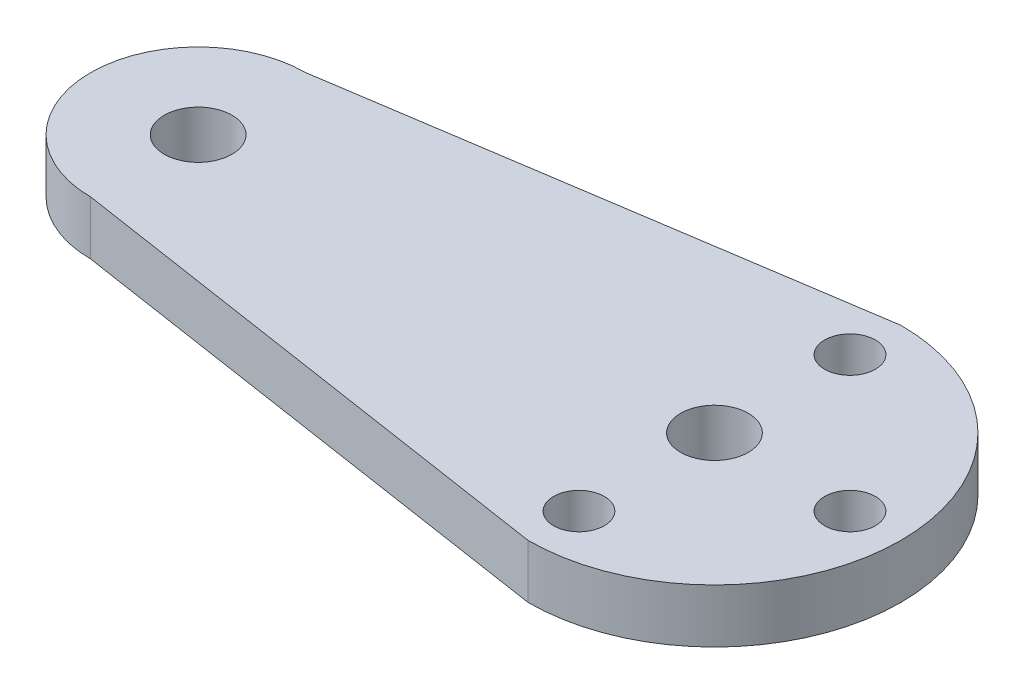
from build123d import *

# Parameters (mm, degrees)
SKETCH1_R           = 2.000000064
SKETCH1_R_2         = 1.5
BOSS_EXTRUDE1_DEPTH = 3.175


with BuildPart() as part:
    # Sketch1 → Boss-Extrude1 (new body)
    with BuildSketch(Plane(origin=(0, 0, 0), x_dir=(1, 0, 0), z_dir=(0, 1, 0))):
        with BuildLine():
            Line((15.24, -11), (-15.24, -6.35))
            ThreePointArc((-15.24, -6.35), (-21.59, 0), (-15.24, 6.35))
            Line((-15.24, 6.35), (15.24, 11))
            ThreePointArc((15.24, 11), (26.24, 0), (15.24, -11))
        make_face()
        with Locations((-15.24, 0)):
            Circle(SKETCH1_R, mode=Mode.SUBTRACT)
        with Locations((15.24, 0)):
            Circle(SKETCH1_R, mode=Mode.SUBTRACT)
        with Locations((15.24, 8)):
            Circle(SKETCH1_R_2, mode=Mode.SUBTRACT)
        with Locations((23.24, 0)):
            Circle(SKETCH1_R_2, mode=Mode.SUBTRACT)
        with Locations((15.24, -8)):
            Circle(SKETCH1_R_2, mode=Mode.SUBTRACT)
    extrude(amount=BOSS_EXTRUDE1_DEPTH)


solid = part.part
